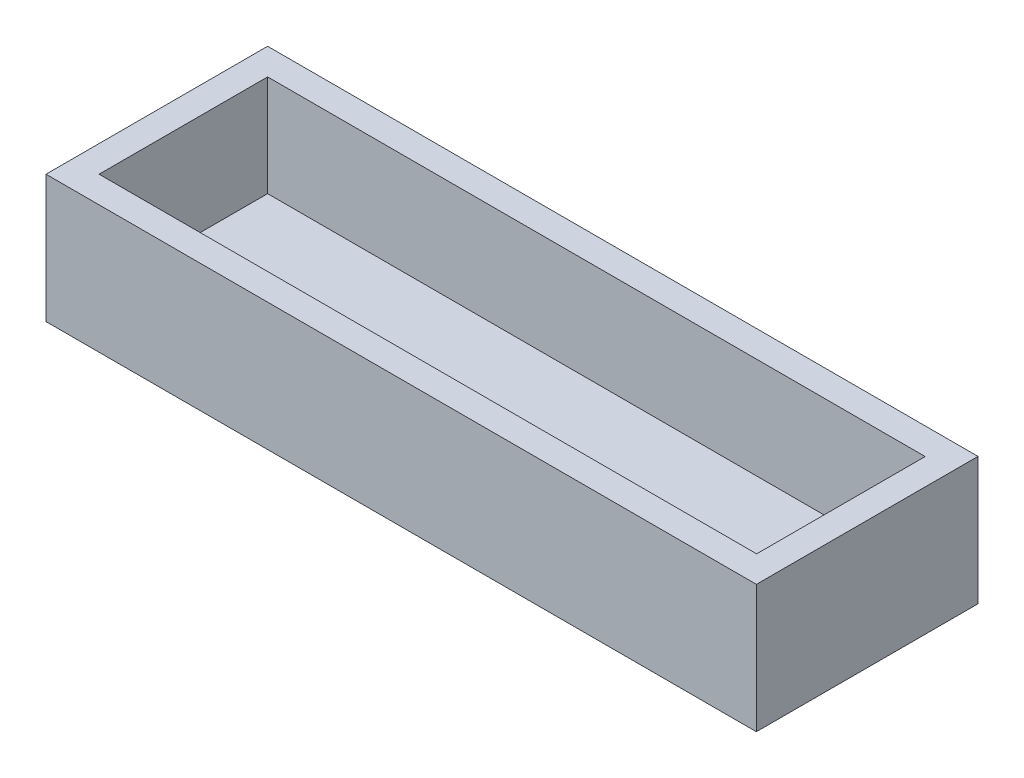
from build123d import *

# Parameters (mm, degrees)
SKETCH2_W           = 267.6500108
SKETCH2_H           = 83.5000108
BOSS_EXTRUDE2_DEPTH = 10
SKETCH3_W           = 267.6500108
SKETCH3_H           = 83.5000108
SKETCH3_W_2         = 247.7440108
SKETCH3_H_2         = 63.5000108
BOSS_EXTRUDE3_DEPTH = 38.1


with BuildPart() as part:
    # Sketch2 → Boss-Extrude2 (new body)
    with BuildSketch(Plane(origin=(0, 0, 0), x_dir=(1, 0, 0), z_dir=(0, 1, 0))):
        Rectangle(SKETCH2_W, SKETCH2_H)
    extrude(amount=BOSS_EXTRUDE2_DEPTH)

    # Sketch3 → Boss-Extrude3 (add)
    with BuildSketch(Plane(origin=(0, 10, 0), x_dir=(1, 0, 0), z_dir=(0, 1, 0))):
        Rectangle(SKETCH3_W, SKETCH3_H)
        with Locations((0.047, 0)):
            Rectangle(SKETCH3_W_2, SKETCH3_H_2, mode=Mode.SUBTRACT)
    extrude(amount=BOSS_EXTRUDE3_DEPTH)


solid = part.part
